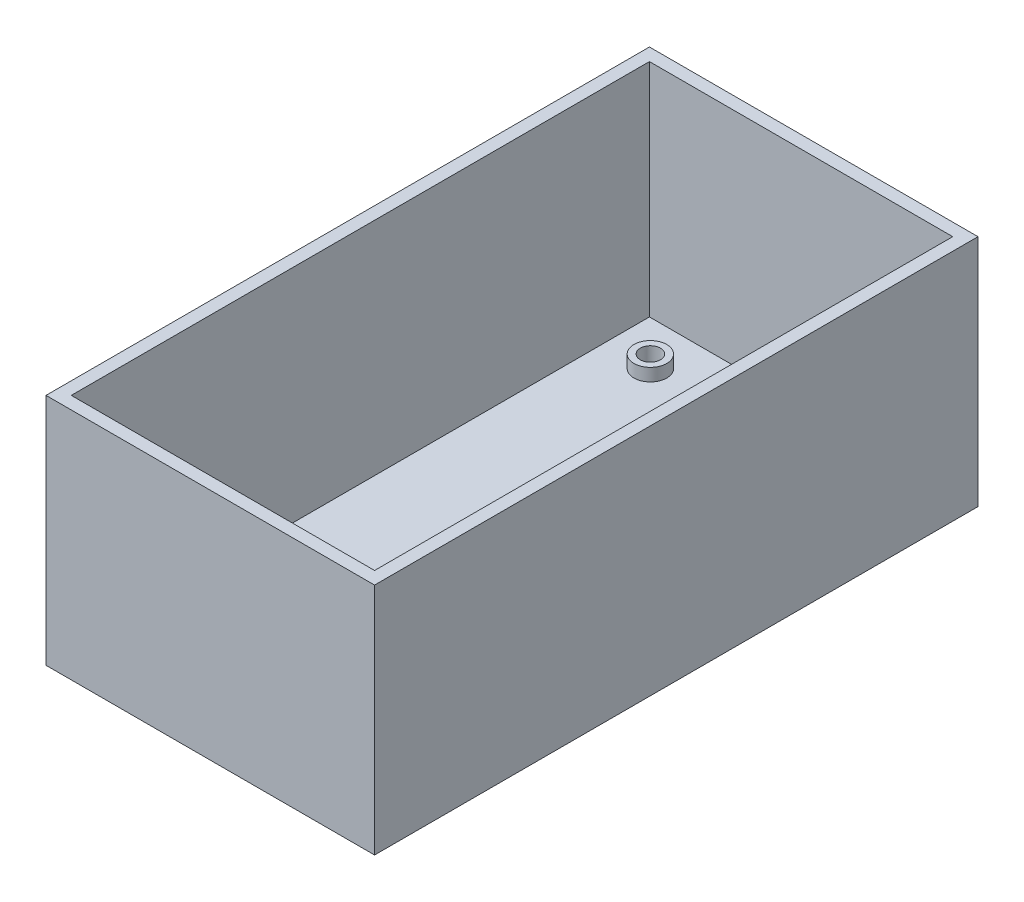
from build123d import *

# Parameters (mm, degrees)
SKETCH1_W           = 52
SKETCH1_H           = 95.5
BOSS_EXTRUDE1_DEPTH = 2
SKETCH2_R           = 1.6
CUT_EXTRUDE1_DEPTH  = 2
SKETCH3_W           = 52
SKETCH3_H           = 95.5
SKETCH3_W_2         = 48
SKETCH3_H_2         = 91.5
BOSS_EXTRUDE2_DEPTH = 35
SKETCH4_R           = 2.6
SKETCH4_R_2         = 1.6
BOSS_EXTRUDE3_DEPTH = 2


with BuildPart() as part:
    # Sketch1 → Boss-Extrude1 (new body)
    with BuildSketch(Plane(origin=(0, 0, 0), x_dir=(1, 0, 0), z_dir=(0, 1, 0))):
        Rectangle(SKETCH1_W, SKETCH1_H)
    extrude(amount=BOSS_EXTRUDE1_DEPTH)

    # Sketch2 → Cut-Extrude1 (cut)
    with BuildSketch(Plane(origin=(0, 2, 0), x_dir=(1, 0, 0), z_dir=(0, 1, 0))):
        with Locations((-16.85, 38.75)):
            Circle(SKETCH2_R)
        with Locations((16.85, 38.75)):
            Circle(SKETCH2_R)
        with Locations((-16.85, -38.75)):
            Circle(SKETCH2_R)
        with Locations((16.85, -38.75)):
            Circle(SKETCH2_R)
    extrude(amount=-CUT_EXTRUDE1_DEPTH, mode=Mode.SUBTRACT)

    # Sketch3 → Boss-Extrude2 (add)
    with BuildSketch(Plane(origin=(0, 2, 0), x_dir=(1, 0, 0), z_dir=(0, 1, 0))):
        Rectangle(SKETCH3_W, SKETCH3_H)
        Rectangle(SKETCH3_W_2, SKETCH3_H_2, mode=Mode.SUBTRACT)
    extrude(amount=BOSS_EXTRUDE2_DEPTH)

    # Sketch4 → Boss-Extrude3 (add)
    with BuildSketch(Plane(origin=(0, 2, 0), x_dir=(1, 0, 0), z_dir=(0, 1, 0))):
        with Locations((-16.85, 38.75)):
            Circle(SKETCH4_R)
        with Locations((-16.85, 38.75)):
            Circle(SKETCH4_R_2, mode=Mode.SUBTRACT)
        with Locations((16.85, 38.75)):
            Circle(SKETCH4_R)
        with Locations((16.85, 38.75)):
            Circle(SKETCH4_R_2, mode=Mode.SUBTRACT)
        with Locations((16.85, -38.75)):
            Circle(SKETCH4_R)
        with Locations((16.85, -38.75)):
            Circle(SKETCH4_R_2, mode=Mode.SUBTRACT)
        with Locations((-16.85, -38.75)):
            Circle(SKETCH4_R)
        with Locations((-16.85, -38.75)):
            Circle(SKETCH4_R_2, mode=Mode.SUBTRACT)
    extrude(amount=BOSS_EXTRUDE3_DEPTH)


solid = part.part
